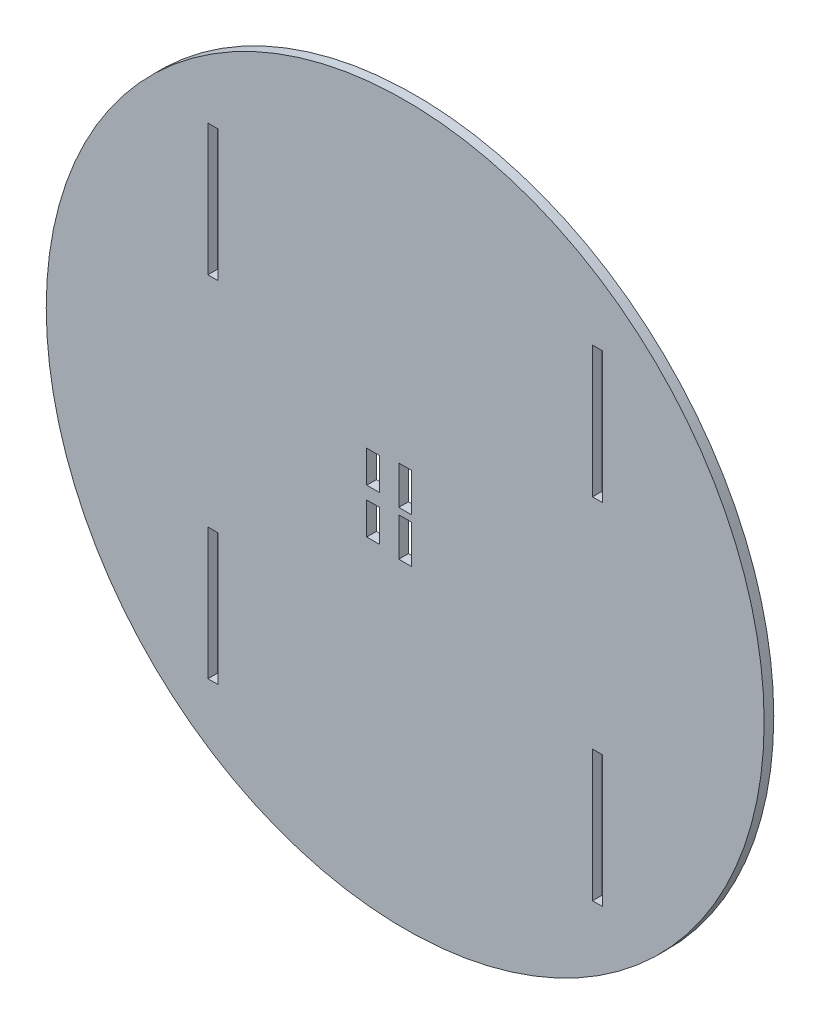
from build123d import *

# Parameters (mm, degrees)
SKETCH1_R           = 112
SKETCH1_W           = 3.1
SKETCH1_H           = 41
SKETCH1_W_2         = 4
SKETCH1_H_2         = 12
SKETCH1_H_3         = 10
BOSS_EXTRUDE1_DEPTH = 1.5


with BuildPart() as part:
    # Sketch1 → Boss-Extrude1 (new body, symmetric)
    with BuildSketch(Plane.XY):
        Circle(SKETCH1_R)
        with Locations((-60, 54.57272334)):
            Rectangle(SKETCH1_W, SKETCH1_H, mode=Mode.SUBTRACT)
        with Locations((-60, -54.57272334)):
            Rectangle(SKETCH1_W, SKETCH1_H, mode=Mode.SUBTRACT)
        with Locations((60, 54.57272334)):
            Rectangle(SKETCH1_W, SKETCH1_H, mode=Mode.SUBTRACT)
        with Locations((60, -54.57272334)):
            Rectangle(SKETCH1_W, SKETCH1_H, mode=Mode.SUBTRACT)
        with Locations((0, 7)):
            Rectangle(SKETCH1_W_2, SKETCH1_H_2, mode=Mode.SUBTRACT)
        with Locations((0, -7)):
            Rectangle(SKETCH1_W_2, SKETCH1_H_2, mode=Mode.SUBTRACT)
        with Locations((-10, 7)):
            Rectangle(SKETCH1_W_2, SKETCH1_H_3, mode=Mode.SUBTRACT)
        with Locations((-10, -7)):
            Rectangle(SKETCH1_W_2, SKETCH1_H_3, mode=Mode.SUBTRACT)
    extrude(amount=BOSS_EXTRUDE1_DEPTH, both=True)


solid = part.part
